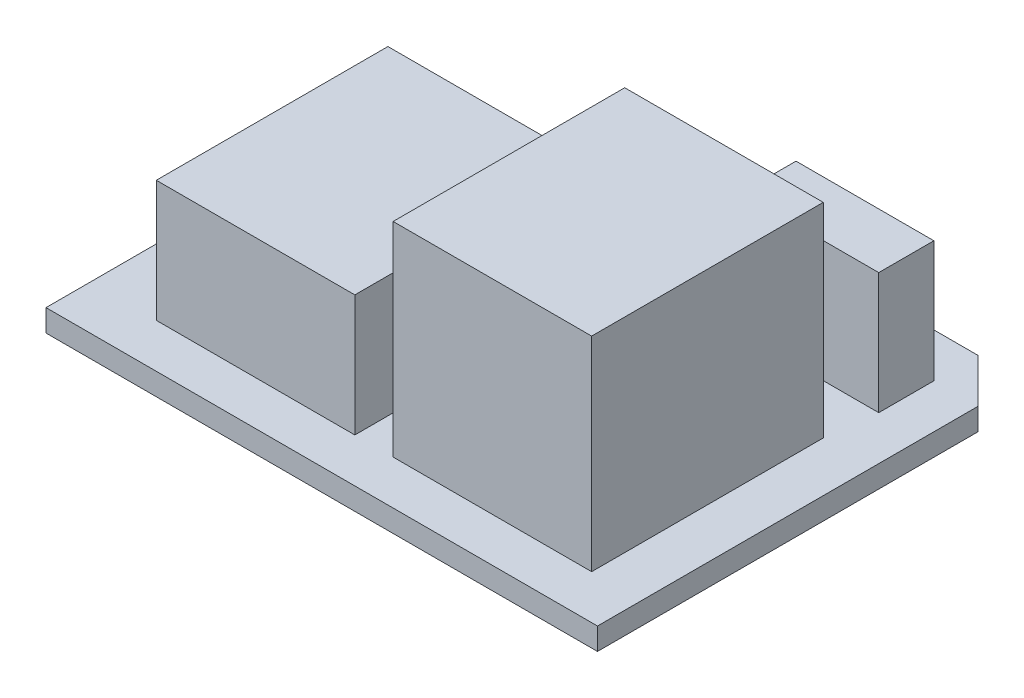
from build123d import *

# Parameters (mm, degrees)
BOSS_EXTRUDE1_DEPTH = 2
SKETCH2_W           = 18
SKETCH2_H           = 21
BOSS_EXTRUDE2_DEPTH = 11
SKETCH3_W           = 18
SKETCH3_H           = 21
BOSS_EXTRUDE3_DEPTH = 18.5
SKETCH4_W           = 12.5
SKETCH4_H           = 5
BOSS_EXTRUDE4_DEPTH = 11


with BuildPart() as part:
    # Sketch1 → Boss-Extrude1 (new body)
    with BuildSketch(Plane(origin=(0, 0, 0), x_dir=(1, 0, 0), z_dir=(0, 1, 0))):
        Polygon((-1, 12.75), (-20, 12.75), (-25, 7.75), (-25, -19.25), (25, -19.25), (25, 15.25), (21, 19.25), (5.5, 19.25), align=None)
    extrude(amount=BOSS_EXTRUDE1_DEPTH)

    # Sketch2 → Boss-Extrude2 (add)
    with BuildSketch(Plane(origin=(0, 2, 0), x_dir=(1, 0, 0), z_dir=(0, 1, 0))):
        with Locations((-10, -4.75)):
            Rectangle(SKETCH2_W, SKETCH2_H)
    extrude(amount=BOSS_EXTRUDE2_DEPTH)

    # Sketch3 → Boss-Extrude3 (add)
    with BuildSketch(Plane(origin=(0, 2, 0), x_dir=(1, 0, 0), z_dir=(0, 1, 0))):
        with Locations((11.471056506, -4.75)):
            Rectangle(SKETCH3_W, SKETCH3_H)
    extrude(amount=BOSS_EXTRUDE3_DEPTH)

    # Sketch4 → Boss-Extrude4 (add)
    with BuildSketch(Plane(origin=(0, 2, 0), x_dir=(1, 0, 0), z_dir=(0, 1, 0))):
        with Locations((14.75, 12.75)):
            Rectangle(SKETCH4_W, SKETCH4_H)
    extrude(amount=BOSS_EXTRUDE4_DEPTH)


solid = part.part
